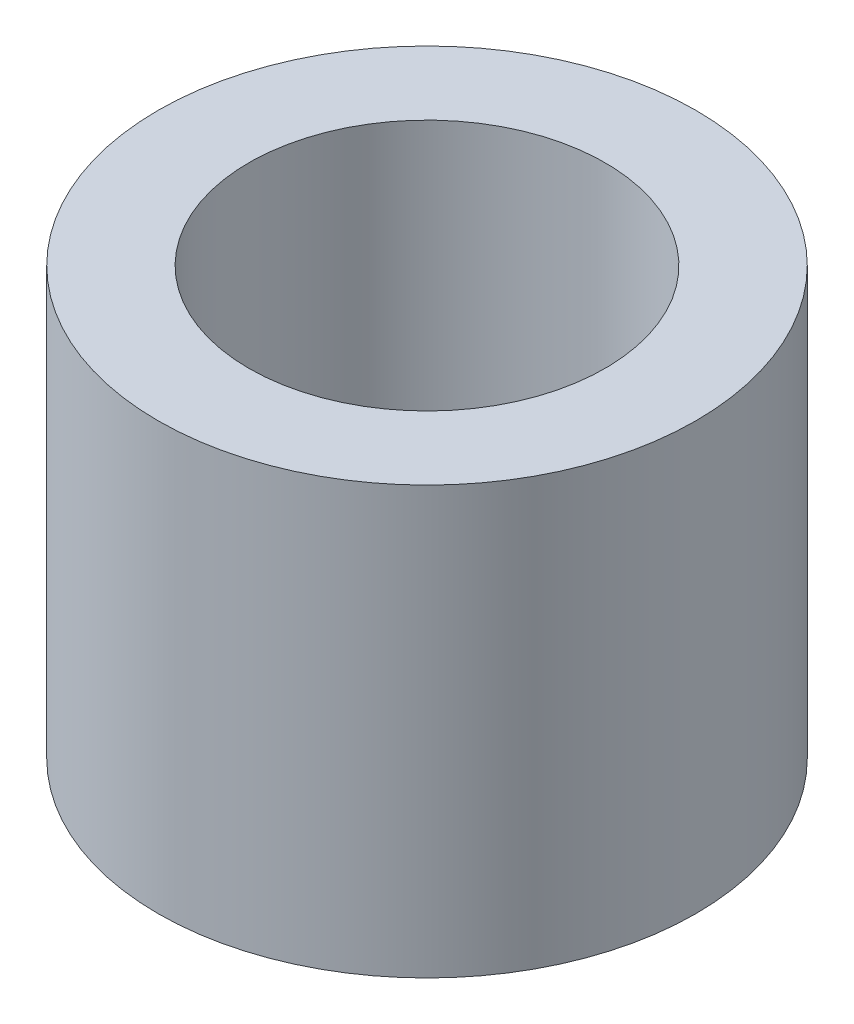
from build123d import *

# Parameters (mm, degrees)
SKETCH1_R           = 4
SKETCH1_R_2         = 2.65
BOSS_EXTRUDE1_DEPTH = 6.35


with BuildPart() as part:
    # Sketch1 → Boss-Extrude1 (new body)
    with BuildSketch(Plane(origin=(0, 0, 0), x_dir=(1, 0, 0), z_dir=(0, 1, 0))):
        Circle(SKETCH1_R)
        Circle(SKETCH1_R_2, mode=Mode.SUBTRACT)
    extrude(amount=BOSS_EXTRUDE1_DEPTH)


solid = part.part
